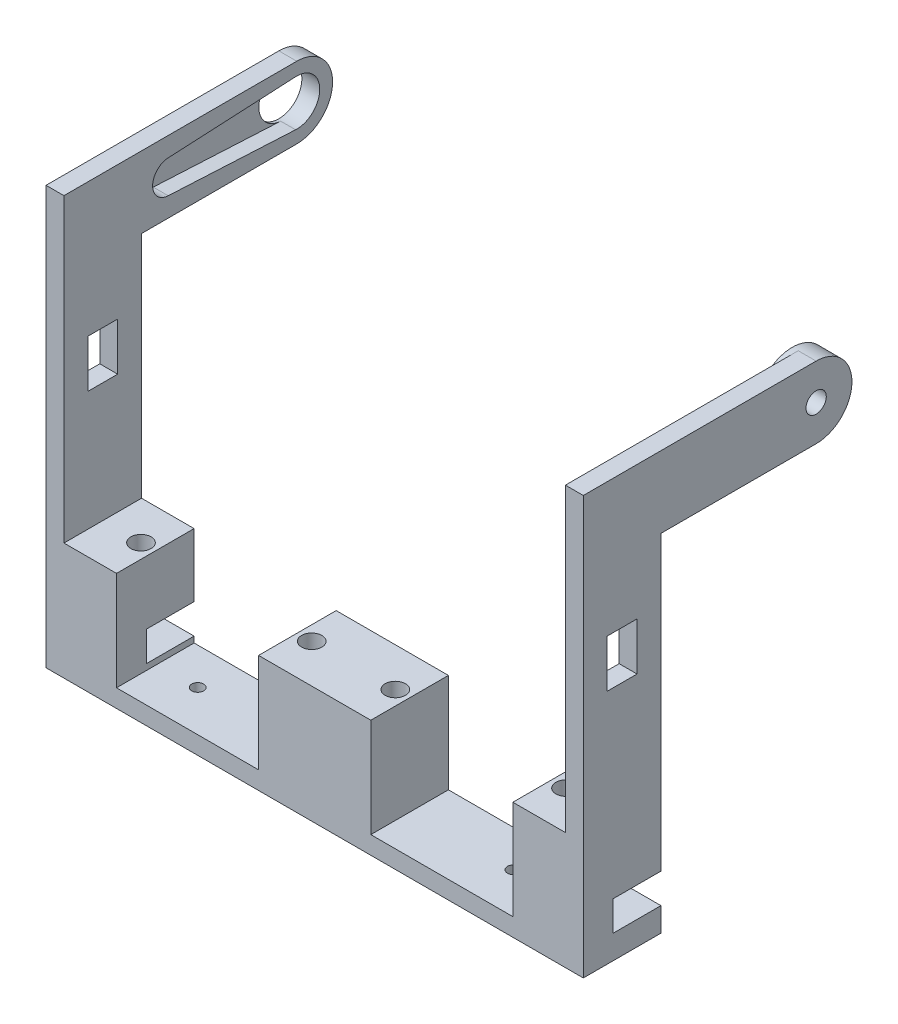
from build123d import *

# Parameters (mm, degrees)
AUFSATZ_LINEAR_AUSTRAGEN1_DEPTH  = 13
AUFSATZ_LINEAR_START             = -13
SKIZZE2_W                        = 3
SKIZZE2_H                        = 12
AUFSATZ_LINEAR_AUSTRAGEN2_DEPTH  = 45
SKIZZE3_W                        = 8.8
SKIZZE3_H                        = 13
SKIZZE3_W_2                      = 18.8
AUFSATZ_LINEAR_AUSTRAGEN3_DEPTH  = 16.6
SKIZZE4_R                        = 1.7
SCHNITT_LINEAR_AUSTRAGEN1_DEPTH  = 4
SKIZZE6_R                        = 1.5
SCHNITT_LINEAR_AUSTRAGEN2_DEPTH  = 4
SCHNITT_LINEAR_START             = -3
SCHNITT_LINEAR_AUSTRAGEN4_DEPTH  = 2.5
SCHNITT_LINEAR_AUSTRAGEN6_DEPTH  = 91
SCHNITT_LINEAR_AUSTRAGEN7_REACH  = 2.5
SKIZZE11_R                       = 3.85
SCHNITT_LINEAR_START_2           = -15
SKIZZE12_W                       = 8
SKIZZE12_H                       = 5
SCHNITT_LINEAR_AUSTRAGEN8_DEPTH  = 16
SKIZZE13_W                       = 5
SKIZZE13_H                       = 8
SCHNITT_LINEAR_AUSTRAGEN9_DEPTH  = 91
SKIZZE14_R                       = 1
SCHNITT_LINEAR_AUSTRAGEN10_DEPTH = 71
AUFSATZ_LINEAR_START_2           = -3
SKIZZE15_R                       = 6
AUFSATZ_LINEAR_AUSTRAGEN4_DEPTH  = 4
SKIZZE16_R                       = 1.7
SCHNITT_LINEAR_AUSTRAGEN11_DEPTH = 3


with BuildPart() as part:
    # Skizze1 → Aufsatz-Linear austragen1 (new body)
    with BuildSketch(Plane.XY):
        Polygon((-45, 67), (-42, 67), (-42, 0), (42, 0), (42, 67), (45, 67), (45, -3), (-45, -3), align=None)
    extrude(amount=AUFSATZ_LINEAR_AUSTRAGEN1_DEPTH)

    # Skizze2 → Aufsatz-Linear austragen2 (add)
    with BuildSketch(Plane(origin=(0, 0, 0), x_dir=(-1, 0, 0), z_dir=(0, 0, -1)).offset(AUFSATZ_LINEAR_START)):
        with Locations((-43.5, 61)):
            Rectangle(SKIZZE2_W, SKIZZE2_H)
        with Locations((43.5, 61)):
            Rectangle(SKIZZE2_W, SKIZZE2_H)
    extrude(amount=AUFSATZ_LINEAR_AUSTRAGEN2_DEPTH)

    # Skizze3 → Aufsatz-Linear austragen3 (add)
    with BuildSketch(Plane(origin=(0, 0, 0), x_dir=(1, 0, 0), z_dir=(0, 1, 0))):
        with Locations((-37.6, -6.5)):
            Rectangle(SKIZZE3_W, SKIZZE3_H)
        with Locations((37.6, -6.5)):
            Rectangle(SKIZZE3_W, SKIZZE3_H)
        with Locations((0, -6.5)):
            Rectangle(SKIZZE3_W_2, SKIZZE3_H)
    extrude(amount=AUFSATZ_LINEAR_AUSTRAGEN3_DEPTH)

    # Skizze4 → Schnitt-Linear austragen1 (cut)
    with BuildSketch(Plane(origin=(0, 16.6, 0), x_dir=(1, 0, 0), z_dir=(0, 1, 0))):
        with Locations((-35.6, -6.5)):
            Circle(SKIZZE4_R)
        with Locations((-7, -6.5)):
            Circle(SKIZZE4_R)
        with Locations((7, -6.5)):
            Circle(SKIZZE4_R)
        with Locations((35.6, -6.5)):
            Circle(SKIZZE4_R)
    extrude(amount=-SCHNITT_LINEAR_AUSTRAGEN1_DEPTH, mode=Mode.SUBTRACT)

    # Skizze6 → Schnitt-Linear austragen2 (cut, through all)
    with BuildSketch(Plane.ZY.offset(-42)):
        with Locations((-26, 61)):
            Circle(SKIZZE6_R)
    extrude(amount=-SCHNITT_LINEAR_AUSTRAGEN2_DEPTH, mode=Mode.SUBTRACT)

    # Skizze7 → Schnitt-Linear austragen4 (cut)
    with BuildSketch(Plane.ZY.offset(45).offset(SCHNITT_LINEAR_START)):
        with BuildLine():
            Line((-25.802102804, 64.844910493), (-4.45864486, 63.746364638))
            ThreePointArc((-4.45864486, 63.746364638), (-1.85, 61), (-4.45864486, 58.253635362))
            Line((-4.45864486, 58.253635362), (-25.802102804, 57.155089507))
            ThreePointArc((-25.802102804, 57.155089507), (-29.85, 61), (-25.802102804, 64.844910493))
        make_face()
    extrude(amount=SCHNITT_LINEAR_AUSTRAGEN4_DEPTH, mode=Mode.SUBTRACT)

    # Skizze10 → Schnitt-Linear austragen6 (cut, through all)
    with BuildSketch(Plane.ZY.offset(45)):
        with BuildLine():
            Line((-26, 55), (-40.113250667, 55))
            Line((-40.113250667, 55), (-40.113250667, 67))
            Line((-40.113250667, 67), (-26, 67))
            ThreePointArc((-26, 67), (-32, 61), (-26, 55))
        make_face()
    extrude(amount=-SCHNITT_LINEAR_AUSTRAGEN6_DEPTH, mode=Mode.SUBTRACT)

    # Skizze11 → Schnitt-Linear austragen7 (cut, up to next)
    with BuildSketch(Plane(origin=(-44.5, 0, 0), x_dir=(0, 0, -1), z_dir=(1, 0, 0)), mode=Mode.PRIVATE) as schnitt_linear_austragen7_sk1:
        with Locations((26, 61)):
            Circle(SKIZZE11_R)
    schnitt_linear_austragen7_tool1 = extrude(schnitt_linear_austragen7_sk1.sketch, amount=-SCHNITT_LINEAR_AUSTRAGEN7_REACH, mode=Mode.PRIVATE) & part.part
    add(schnitt_linear_austragen7_tool1.solids().sort_by_distance((-44.5, 61, -26))[0], mode=Mode.SUBTRACT)

    # Skizze12 → Schnitt-Linear austragen8 (cut)
    with BuildSketch(Plane(origin=(45, 0, 0), x_dir=(0, 0, -1), z_dir=(1, 0, 0)).offset(SCHNITT_LINEAR_START_2)):
        with Locations((-4, 3.5)):
            Rectangle(SKIZZE12_W, SKIZZE12_H)
    schnitt_linear_austragen8 = extrude(amount=SCHNITT_LINEAR_AUSTRAGEN8_DEPTH, mode=Mode.SUBTRACT)

    # Spiegeln1: Schnitt-Linear austragen8 across plane
    add(schnitt_linear_austragen8.mirror(Plane.ZY), mode=Mode.SUBTRACT)

    # Skizze13 → Schnitt-Linear austragen9 (cut, through all)
    with BuildSketch(Plane.ZY.offset(45)):
        with Locations((6.5, 40.6)):
            Rectangle(SKIZZE13_W, SKIZZE13_H)
    extrude(amount=-SCHNITT_LINEAR_AUSTRAGEN9_DEPTH, mode=Mode.SUBTRACT)

    # Skizze14 → Schnitt-Linear austragen10 (cut, through all)
    with BuildSketch(Plane(origin=(0, -3, 0), x_dir=(-1, 0, 0), z_dir=(0, -1, 0))):
        with Locations((26.45, -6.15)):
            Circle(SKIZZE14_R)
        with Locations((-26.45, -6.15)):
            Circle(SKIZZE14_R)
    extrude(amount=-SCHNITT_LINEAR_AUSTRAGEN10_DEPTH, mode=Mode.SUBTRACT)

    # Skizze15 → Aufsatz-Linear austragen4 (add)
    with BuildSketch(Plane.ZY.offset(-42).offset(AUFSATZ_LINEAR_START_2)):
        with Locations((-26, 61)):
            Circle(SKIZZE15_R)
    extrude(amount=AUFSATZ_LINEAR_AUSTRAGEN4_DEPTH)

    # Skizze16 → Schnitt-Linear austragen11 (cut)
    with BuildSketch(Plane(origin=(45, 0, 0), x_dir=(0, 0, -1), z_dir=(1, 0, 0))):
        with Locations((26, 61)):
            Circle(SKIZZE16_R)
    extrude(amount=-SCHNITT_LINEAR_AUSTRAGEN11_DEPTH, mode=Mode.SUBTRACT)


solid = part.part
